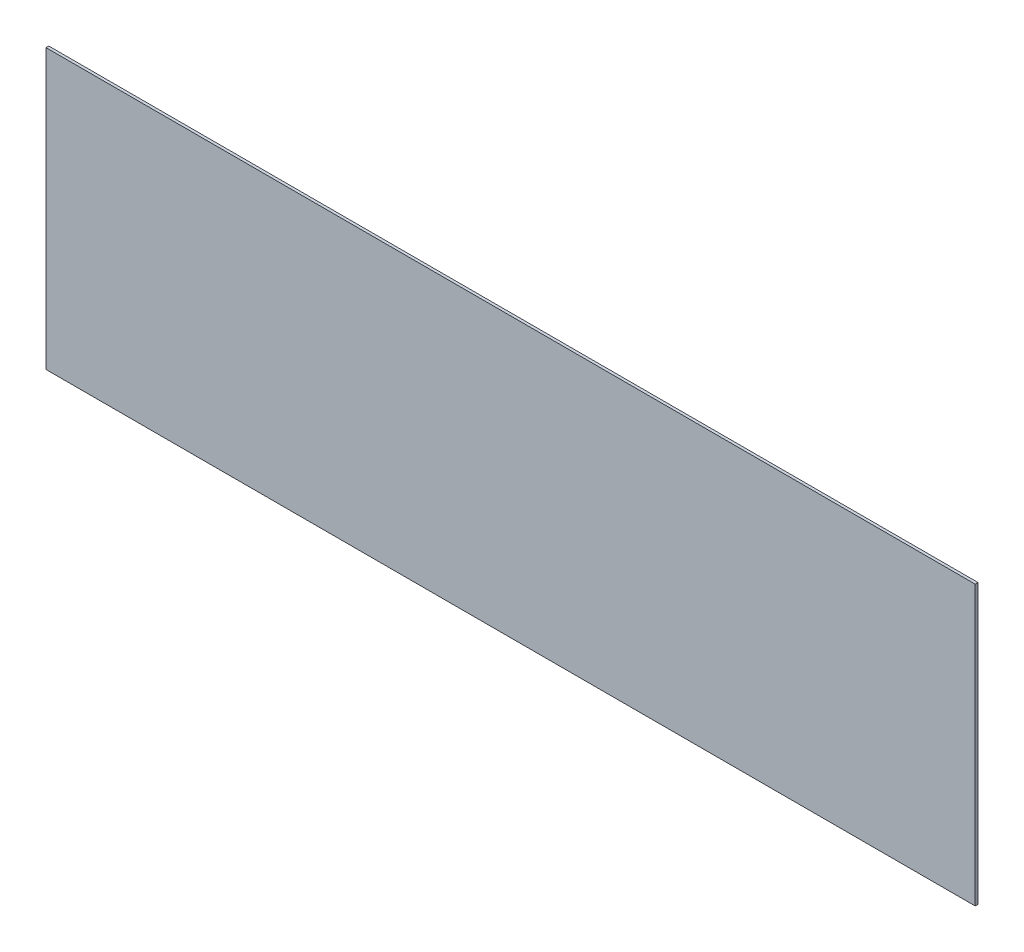
from build123d import *

# Parameters (mm, degrees)
SKETCH1_W           = 500
SKETCH1_H           = 150
BOSS_EXTRUDE1_DEPTH = 1.5


with BuildPart() as part:
    # Sketch1 → Boss-Extrude1 (new body)
    with BuildSketch(Plane.XY):
        with Locations((250, -75)):
            Rectangle(SKETCH1_W, SKETCH1_H)
    extrude(amount=BOSS_EXTRUDE1_DEPTH)


solid = part.part
